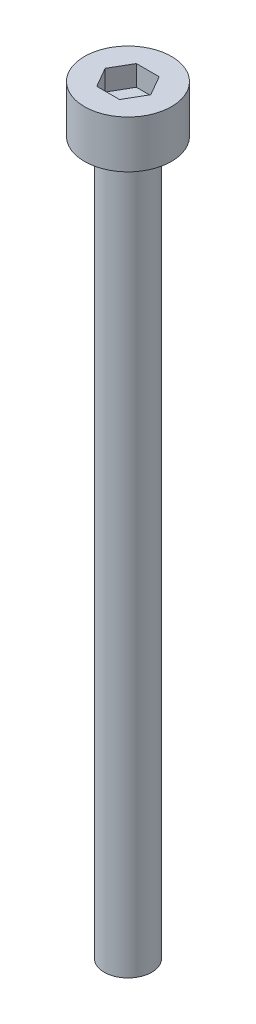
from build123d import *

# Parameters (mm, degrees)
SKETCH_1_R            = 2.75
EXTRUDE_248_DEPTH     = 3
CUT_EXTRUDE_378_DEPTH = 1.3
SKETCH_3_R            = 1.5
EXTRUDE_479_DEPTH     = 45


with BuildPart() as part:
    # 草图1 → Extrude 248 (new body)
    with BuildSketch(Plane(origin=(0, 0, 0), x_dir=(1, 0, 0), z_dir=(0, 1, 0))):
        Circle(SKETCH_1_R)
    extrude(amount=EXTRUDE_248_DEPTH)

    # 草图2 → Cut-Extrude 378 (cut)
    with BuildSketch(Plane(origin=(0, 3, 0), x_dir=(1, 0, 0), z_dir=(0, 1, 0))):
        Polygon((1.443375673, 0), (0.721687836, 1.25), (-0.721687836, 1.25), (-1.443375673, 0), (-0.721687836, -1.25), (0.721687836, -1.25), align=None)
    extrude(amount=-CUT_EXTRUDE_378_DEPTH, mode=Mode.SUBTRACT)

    # 草图3 → Extrude 479 (add)
    with BuildSketch(Plane.XZ):
        Circle(SKETCH_3_R)
    extrude(amount=EXTRUDE_479_DEPTH)


solid = part.part
